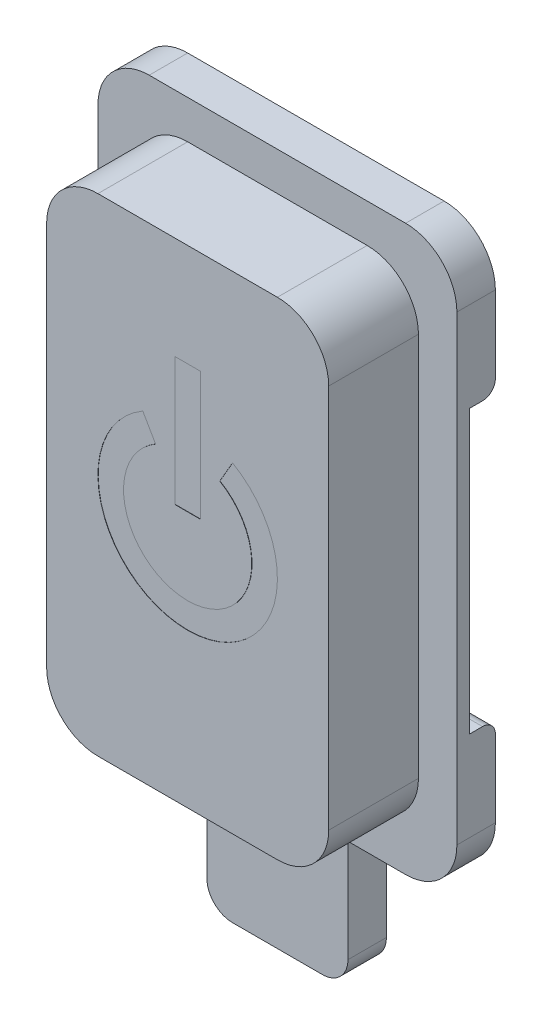
from build123d import *

# Parameters (mm, degrees)
SKETCH_1_W           = 14
SKETCH_1_H           = 22
EXTRUDE_1_DEPTH      = 5
SKETCH_2_OUTSIDE_W   = 21.31
SKETCH_2_OUTSIDE_H   = 29.31
SKETCH_2_OUTSIDE_W_2 = 11
SKETCH_2_OUTSIDE_H_2 = 19
CUT_EXTRUDE_1_DEPTH  = 3.5
SKETCH_3_W           = 8
SKETCH_3_H           = 16
CUT_EXTRUDE_2_DEPTH  = 3
SKETCH_4_W           = 5.5
SKETCH_4_H           = 5
EXTRUDE_2_DEPTH      = 1.5
FILLET_1_R           = 2
FILLET_2_R           = 1
EXTRUDE_3_DEPTH      = 4
SKETCH_6_W           = 1
SKETCH_6_H           = 5
CUT_EXTRUDE_3_DEPTH  = 0.01
SKETCH_7_W           = 3
SKETCH_7_H           = 11
CUT_EXTRUDE_4_DEPTH  = 1
FILLET_3_R           = 0.5


with BuildPart() as part:
    # 草图1 → 凸台-拉伸1 (new body)
    with BuildSketch(Plane.XY):
        Rectangle(SKETCH_1_W, SKETCH_1_H)
    extrude(amount=EXTRUDE_1_DEPTH)

    # 草图2 outside → 切除-拉伸1 (cut)
    with BuildSketch(Plane.XY.offset(5)):
        Rectangle(SKETCH_2_OUTSIDE_W, SKETCH_2_OUTSIDE_H)
        Rectangle(SKETCH_2_OUTSIDE_W_2, SKETCH_2_OUTSIDE_H_2, mode=Mode.SUBTRACT)
    extrude(amount=-CUT_EXTRUDE_1_DEPTH, mode=Mode.SUBTRACT)

    # 草图3 → 切除-拉伸2 (cut)
    with BuildSketch(Plane(origin=(0, 0, 0), x_dir=(-1, 0, 0), z_dir=(0, 0, -1))):
        Rectangle(SKETCH_3_W, SKETCH_3_H)
    extrude(amount=-CUT_EXTRUDE_2_DEPTH, mode=Mode.SUBTRACT)

    # 草图4 → 凸台-拉伸2 (add)
    with BuildSketch(Plane(origin=(0, 0, 0), x_dir=(-1, 0, 0), z_dir=(0, 0, -1))):
        with Locations((0, -13.5)):
            Rectangle(SKETCH_4_W, SKETCH_4_H)
    extrude(amount=-EXTRUDE_2_DEPTH)

    # 圆角1
    fillet_1_edges = [part.edges().sort_by_distance(p)[0] for p in [
        (-7, 11, 0.75),
        (7, 11, 0.75),
        (7, -11, 0.75),
        (-7, -11, 0.75),
        (5.5, -9.5, 3.25),
        (-5.5, -9.5, 3.25),
        (-5.5, 9.5, 3.25),
        (5.5, 9.5, 3.25),
    ]]
    fillet(fillet_1_edges, radius=FILLET_1_R)

    # 圆角2
    fillet_2_edges = [part.edges().sort_by_distance(p)[0] for p in [
        (4, -8, 1.5),
        (4, 8, 1.5),
        (-4, 8, 1.5),
        (-4, -8, 1.5),
        (-2.75, -16, 0.75),
        (2.75, -16, 0.75),
    ]]
    fillet(fillet_2_edges, radius=FILLET_2_R)

    # 草图5 → 凸台-拉伸3 (add)
    with BuildSketch(Plane(origin=(0, 0, 0), x_dir=(-1, 0, 0), z_dir=(0, 0, -1))):
        Polygon((-2, -11), (-0.5, -11), (-0.5, -9.5), (0.5, -9.5), (0.5, -11), (2, -11), (2, -12), (0.5, -12), (0.5, -13.5), (-0.5, -13.5), (-0.5, -12), (-2, -12), align=None)
    extrude(amount=EXTRUDE_3_DEPTH)

    # 草图6 → 切除-拉伸3 (cut)
    with BuildSketch(Plane.XY.offset(5)):
        with BuildLine():
            Line((-1.25, 2.165063509), (-1.75, 3.031088913))
            ThreePointArc((-1.75, 3.031088913), (0, -3.5), (1.75, 3.031088913))
            Line((1.75, 3.031088913), (1.25, 2.165063509))
            ThreePointArc((1.25, 2.165063509), (0, -2.5), (-1.25, 2.165063509))
        make_face()
        with Locations((0, 3)):
            Rectangle(SKETCH_6_W, SKETCH_6_H)
    extrude(amount=-CUT_EXTRUDE_3_DEPTH, mode=Mode.SUBTRACT)

    # 草图7 → 切除-拉伸4 (cut)
    with BuildSketch(Plane(origin=(0, 0, 0), x_dir=(-1, 0, 0), z_dir=(0, 0, -1))):
        with Locations((-5.5, 0)):
            Rectangle(SKETCH_7_W, SKETCH_7_H)
    extrude(amount=-CUT_EXTRUDE_4_DEPTH, mode=Mode.SUBTRACT)

    # 圆角3
    fillet_3_edges = [part.edges().sort_by_distance(p)[0] for p in [
        (2, -11.5, -4),
        (0, -13.5, -4),
        (-2, -11.5, -4),
        (0, -9.5, -4),
        (5.5, -5.5, 0),
        (5.5, 5.5, 0),
    ]]
    fillet(fillet_3_edges, radius=FILLET_3_R)


solid = part.part
